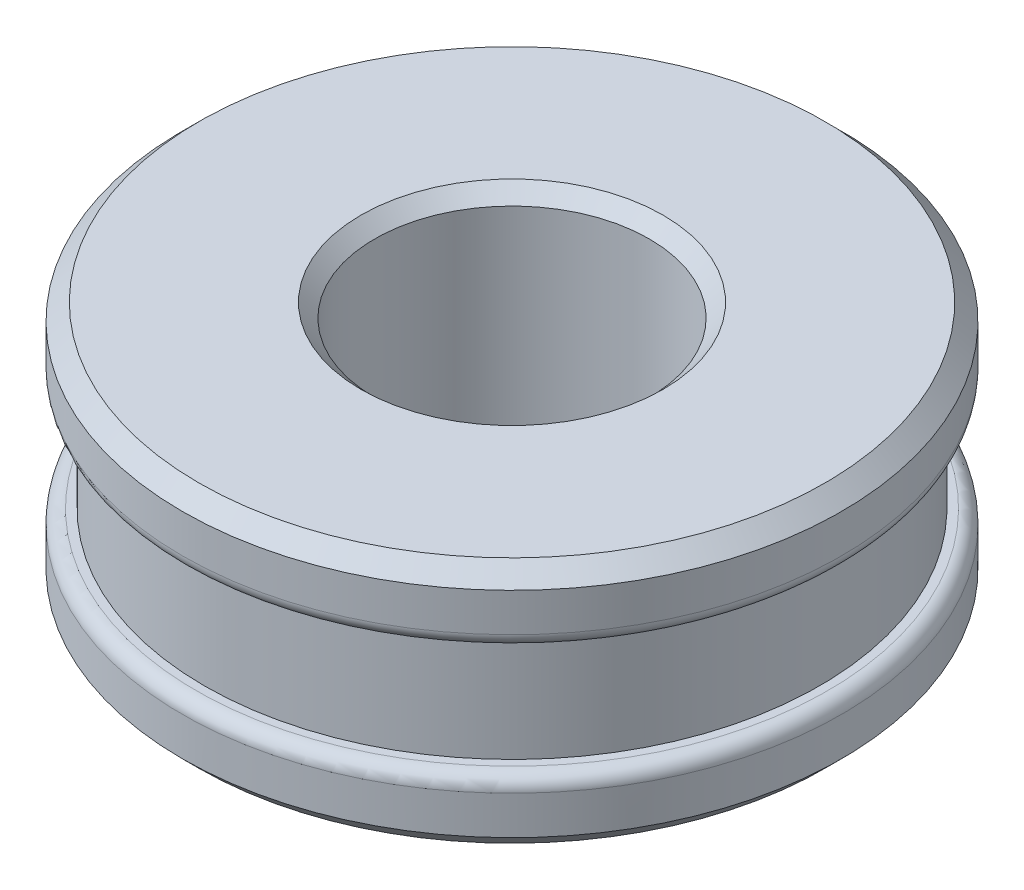
from build123d import *

# Parameters (mm, degrees)
SKETCH_1_R      = 12
SKETCH_1_R_2    = 5
EXTRUDE_1_DEPTH = 9
CHAMFER_1_SIZE  = 0.6
FILLET_1_R      = 0.5
CHAMFER_2_SIZE  = 0.5


with BuildPart() as part:
    # 草图1 → 凸台-拉伸1 (new body)
    with BuildSketch(Plane(origin=(0, 0, 0), x_dir=(1, 0, 0), z_dir=(0, 1, 0))):
        Circle(SKETCH_1_R)
        Circle(SKETCH_1_R_2, mode=Mode.SUBTRACT)
    extrude(amount=EXTRUDE_1_DEPTH)

    # 倒角1
    chamfer_1_edges = [part.edges().sort_by_distance(p)[0] for p in [
        (-12, 0, 0),
        (-12, 9, 0),
    ]]
    chamfer(chamfer_1_edges, length=CHAMFER_1_SIZE)

    # 草图2 → 切除-旋转1 (revolve, cut)
    with BuildSketch(Plane.XY):
        Polygon((12, 6.5), (11.2, 6.5), (11.2, 2.5), (12, 2.5), (14.67598619, 3.734930545), align=None)
    revolve(axis=Axis((0, 0, 0), (0, 1, 0)), mode=Mode.SUBTRACT)

    # 圆角1
    fillet_1_edges = [part.edges().sort_by_distance(p)[0] for p in [
        (-12, 6.5, 0),
        (-12, 2.5, 0),
    ]]
    fillet(fillet_1_edges, radius=FILLET_1_R)

    # 倒角2
    chamfer_2_edges = [part.edges().sort_by_distance(p)[0] for p in [
        (-5, 0, 0),
        (-5, 9, 0),
    ]]
    chamfer(chamfer_2_edges, length=CHAMFER_2_SIZE)


solid = part.part
